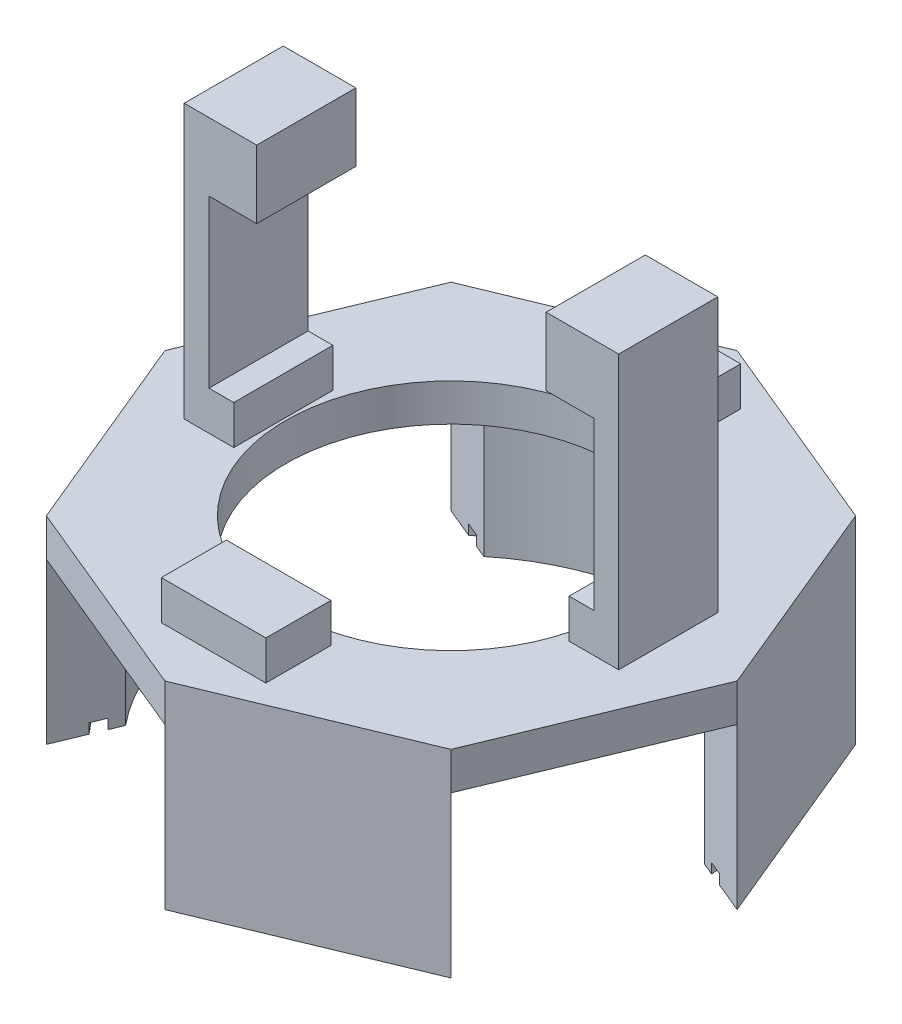
from build123d import *

# Parameters (mm, degrees)
BOSS_EXTRUDE1_DEPTH = 7.61
SKETCH5_R           = 17.78
CUT_EXTRUDE2_DEPTH  = 12.3444
SKETCH6_R           = 12.7
CUT_EXTRUDE3_DEPTH  = 3.8756
SKETCH7_W           = 16.833639174
SKETCH7_H           = 12.3244
CUT_EXTRUDE4_DEPTH  = 50.056819587
SKETCH8_W           = 16.833639174
SKETCH8_H           = 12.3244
CUT_EXTRUDE5_DEPTH  = 50.056819587
SKETCH10_R          = 19.69527877
SKETCH10_R_2        = 18.703643049
CUT_EXTRUDE7_DEPTH  = 0.762
SKETCH11_W          = 3.81
SKETCH11_H          = 7.62
BOSS_EXTRUDE2_DEPTH = 21.02
SKETCH13_W          = 29.591
SKETCH13_H          = 7.62
CUT_EXTRUDE8_DEPTH  = 18.02
SKETCH15_W          = 8.037943886
SKETCH15_H          = 5
BOSS_EXTRUDE3_DEPTH = 3
SKETCH16_W          = 7.62
SKETCH16_H          = 5.23
BOSS_EXTRUDE4_DEPTH = 3.67


with BuildPart() as part:
    # Sketch1 → Boss-Extrude1 (new body, symmetric)
    with BuildSketch(Plane(origin=(0, 0, 0), x_dir=(1, 0, 0), z_dir=(0, 1, 0))):
        Polygon((21.99420951, 0), (15.552254691, 15.552254691), (0, 21.99420951), (-15.552254691, 15.552254691), (-21.99420951, 0), (-15.552254691, -15.552254691), (0, -21.99420951), (15.552254691, -15.552254691), align=None)
    extrude(amount=BOSS_EXTRUDE1_DEPTH, both=True)

    # Sketch5 → Cut-Extrude2 (cut)
    with BuildSketch(Plane.XZ.offset(7.61)):
        Circle(SKETCH5_R)
    extrude(amount=-CUT_EXTRUDE2_DEPTH, mode=Mode.SUBTRACT)

    # Sketch6 → Cut-Extrude3 (cut, through all)
    with BuildSketch(Plane.XZ.offset(-4.7344)):
        Circle(SKETCH6_R)
    extrude(amount=-CUT_EXTRUDE3_DEPTH, mode=Mode.SUBTRACT)

    # Sketch7 → Cut-Extrude4 (cut, through all)
    with BuildSketch(Plane(origin=(-7.776127346, 0, 18.773232101), x_dir=(0.923879533, 0, 0.382683432), z_dir=(-0.382683432, 0, 0.923879533))):
        with Locations((0, -1.4478)):
            Rectangle(SKETCH7_W, SKETCH7_H)
    extrude(amount=-CUT_EXTRUDE4_DEPTH, mode=Mode.SUBTRACT)

    # Sketch8 → Cut-Extrude5 (cut, through all)
    with BuildSketch(Plane(origin=(18.773232101, 0, 7.776127346), x_dir=(0.382683432, 0, -0.923879533), z_dir=(0.923879533, 0, 0.382683432))):
        with Locations((0, -1.4478)):
            Rectangle(SKETCH8_W, SKETCH8_H)
    extrude(amount=-CUT_EXTRUDE5_DEPTH, mode=Mode.SUBTRACT)

    # Sketch10 → Cut-Extrude7 (cut)
    with BuildSketch(Plane.XZ.offset(7.61)):
        Circle(SKETCH10_R)
        Circle(SKETCH10_R_2, mode=Mode.SUBTRACT)
    extrude(amount=-CUT_EXTRUDE7_DEPTH, mode=Mode.SUBTRACT)

    # Sketch11 → Boss-Extrude2 (add)
    with BuildSketch(Plane(origin=(0, 7.61, 0), x_dir=(1, 0, 0), z_dir=(0, 1, 0))):
        with Locations((14.7955, 0)):
            Rectangle(SKETCH11_W, SKETCH11_H)
        with Locations((-14.7955, 0)):
            Rectangle(SKETCH11_W, SKETCH11_H)
    extrude(amount=BOSS_EXTRUDE2_DEPTH)

    # Sketch13 → Cut-Extrude8 (cut)
    with BuildSketch(Plane(origin=(0, 28.63, 0), x_dir=(1, 0, 0), z_dir=(0, 1, 0))):
        Rectangle(SKETCH13_W, SKETCH13_H)
    extrude(amount=-CUT_EXTRUDE8_DEPTH, mode=Mode.SUBTRACT)

    # Sketch15 → Boss-Extrude3 (add)
    with BuildSketch(Plane(origin=(0, 7.61, 0), x_dir=(1, 0, 0), z_dir=(0, 1, 0))):
        with Locations((0, -15.75)):
            Rectangle(SKETCH15_W, SKETCH15_H)
        with Locations((0, 15.75)):
            Rectangle(SKETCH15_W, SKETCH15_H)
    extrude(amount=BOSS_EXTRUDE3_DEPTH)

    # Sketch16 → Boss-Extrude4 (add)
    with BuildSketch(Plane(origin=(-14.7955, 0, 0), x_dir=(0, 0, -1), z_dir=(1, 0, 0))):
        with Locations((0, 26.015)):
            Rectangle(SKETCH16_W, SKETCH16_H)
    boss_extrude4 = extrude(amount=BOSS_EXTRUDE4_DEPTH)

    # Mirror1: Boss-Extrude4 across plane
    add(boss_extrude4.mirror(Plane(origin=(0, 0, 0), x_dir=(0, 0, 1), z_dir=(1, 0, 0))))


solid = part.part
